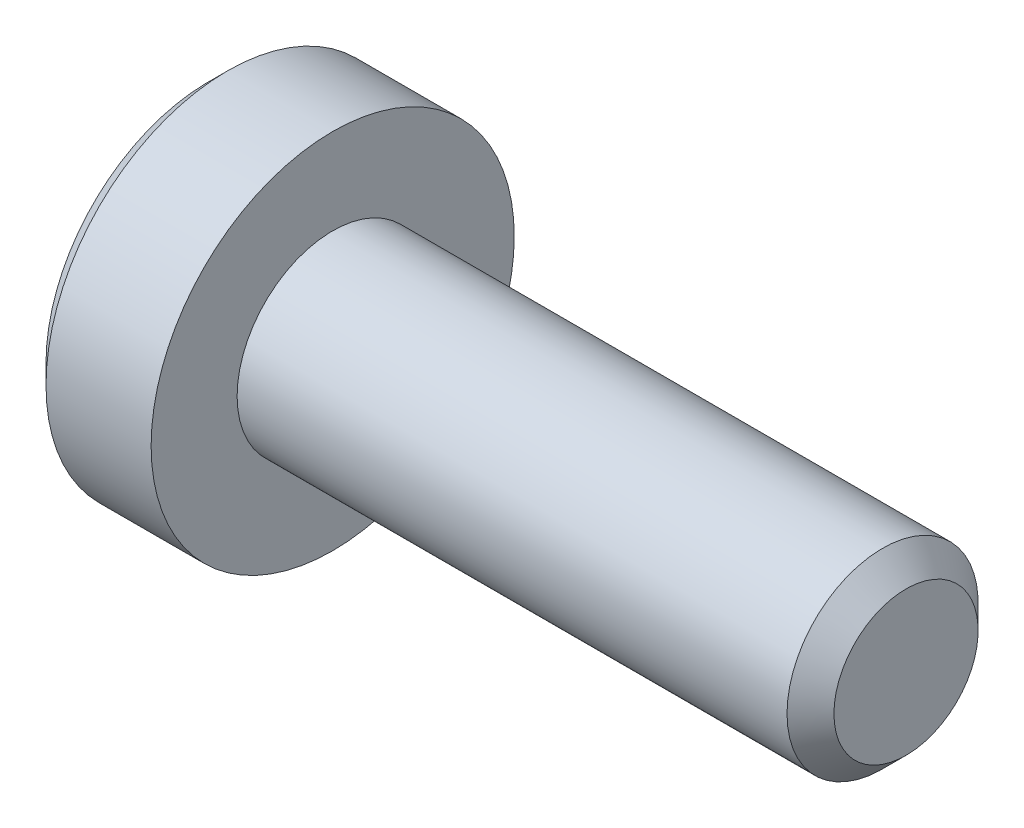
from build123d import *

# Parameters (mm, degrees)
CUT_EXTRUDE1_DEPTH = 0.7


with BuildPart() as part:
    # Sketch1 → Revolve1 (revolve)
    with BuildSketch(Plane.XY):
        Polygon((-1.3, 0), (-1.3, 1.7), (-1.1, 1.9), (0, 1.9), (0, 1), (5.7545, 1), (6, 0.7545), (6, 0), align=None)
    revolve(axis=Axis((6, 0, 0), (-1, 0, 0)))

    # Sketch2 → Cut-Extrude1 (cut)
    with BuildSketch(Plane(origin=(-1.3, 0, 0), x_dir=(0, 0, -1), z_dir=(1, 0, 0))):
        Polygon((-0.65, -0.375277675), (0, -0.75055535), (0.65, -0.375277675), (0.65, 0.375277675), (0, 0.75055535), (-0.65, 0.375277675), align=None)
    extrude(amount=CUT_EXTRUDE1_DEPTH, mode=Mode.SUBTRACT)


solid = part.part
